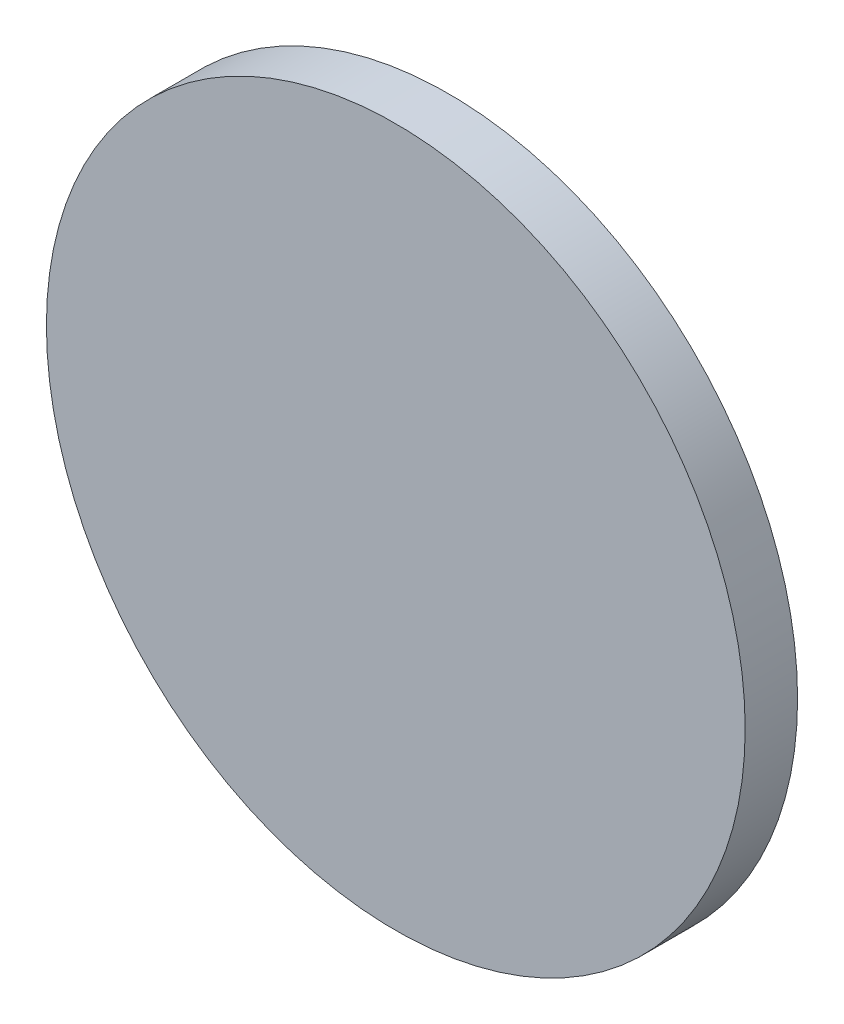
from build123d import *

# Parameters (mm, degrees)
SKETCH1_R           = 20
BOSS_EXTRUDE1_DEPTH = 3


with BuildPart() as part:
    # Sketch1 → Boss-Extrude1 (new body)
    with BuildSketch(Plane.XY):
        Circle(SKETCH1_R)
    extrude(amount=BOSS_EXTRUDE1_DEPTH)


solid = part.part
